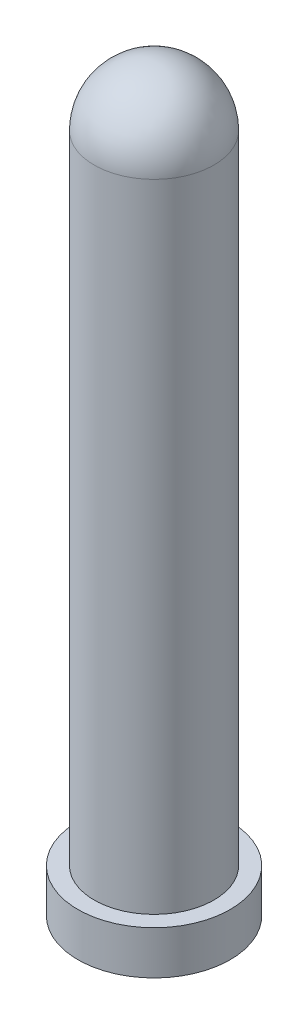
from build123d import *


with BuildPart() as part:
    # Esquisse1 → Révolution1 (revolve)
    with BuildSketch(Plane.XY, mode=Mode.PRIVATE) as r_volution1_sk:
        with BuildLine():
            Line((-1.5, 0), (-1.5, 30))
            Line((-1.5, 30), (0, 30))
            Line((0, 30), (0, 34))
            ThreePointArc((0, 34), (-1.944543648, 33.194543648), (-2.75, 31.25))
            Line((-2.75, 31.25), (-2.75, 2))
            Line((-2.75, 2), (-3.5, 2))
            Line((-3.5, 2), (-3.5, 0))
            Line((-3.5, 0), (-1.5, 0))
        make_face()
    revolve(r_volution1_sk.sketch.rotate(Axis((0, 0, 0), (0, 1, 0)), 270), axis=Axis((0, 0, 0), (0, 1, 0)))  # turned: the seam where the file's is


solid = part.part
